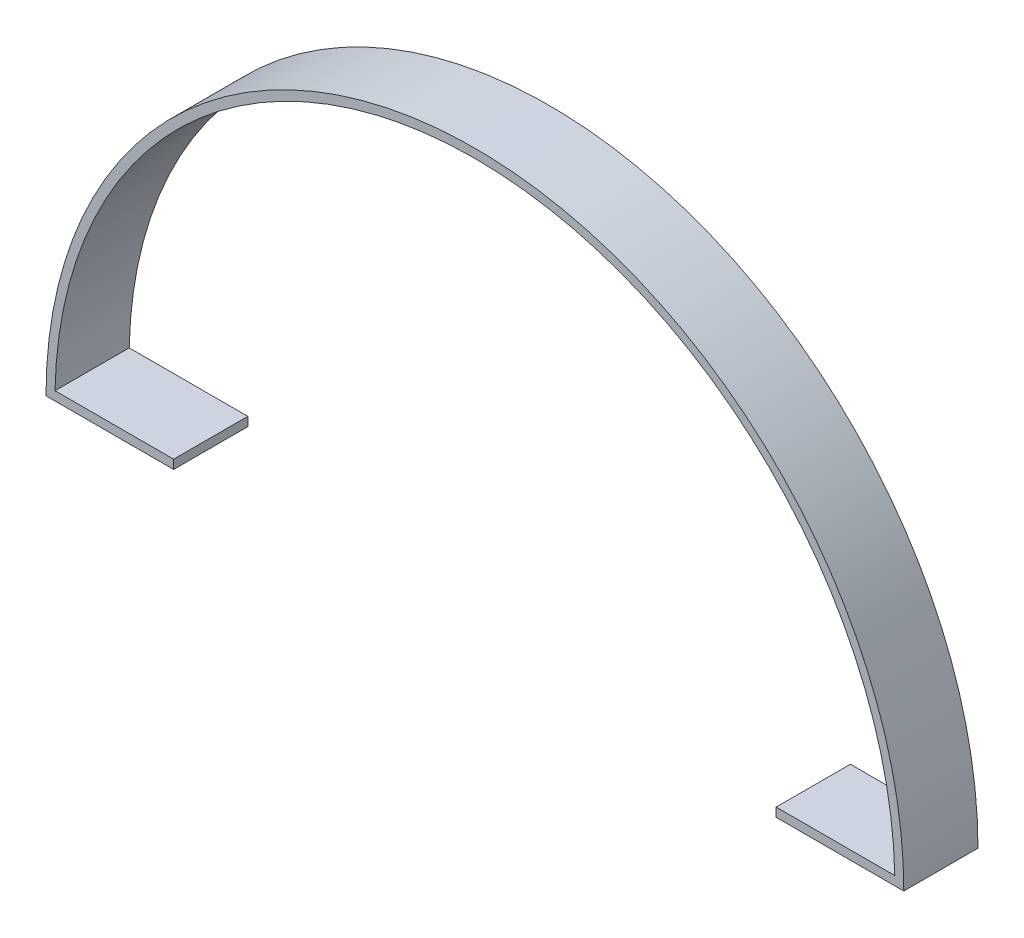
from build123d import *

# Parameters (mm, degrees)
EXTRU_MINCE1_DEPTH = 25


with BuildPart() as part:
    # Esquisse1 → Extru.-Mince1 (new body)
    with BuildSketch(Plane.XY):
        with BuildLine():
            Line((246, 0), (289, 0))
            ThreePointArc((289, 0), (144.5, 144.5), (0, 0))
            Line((0, 0), (43, 0))
            Line((43, 0), (43, 3))
            Line((43, 3), (3.031805695, 3))
            ThreePointArc((3.031805695, 3), (144.5, 141.5), (285.968194305, 3))
            Line((285.968194305, 3), (246, 3))
            Line((246, 3), (246, 0))
        make_face()
    extrude(amount=EXTRU_MINCE1_DEPTH)


solid = part.part
